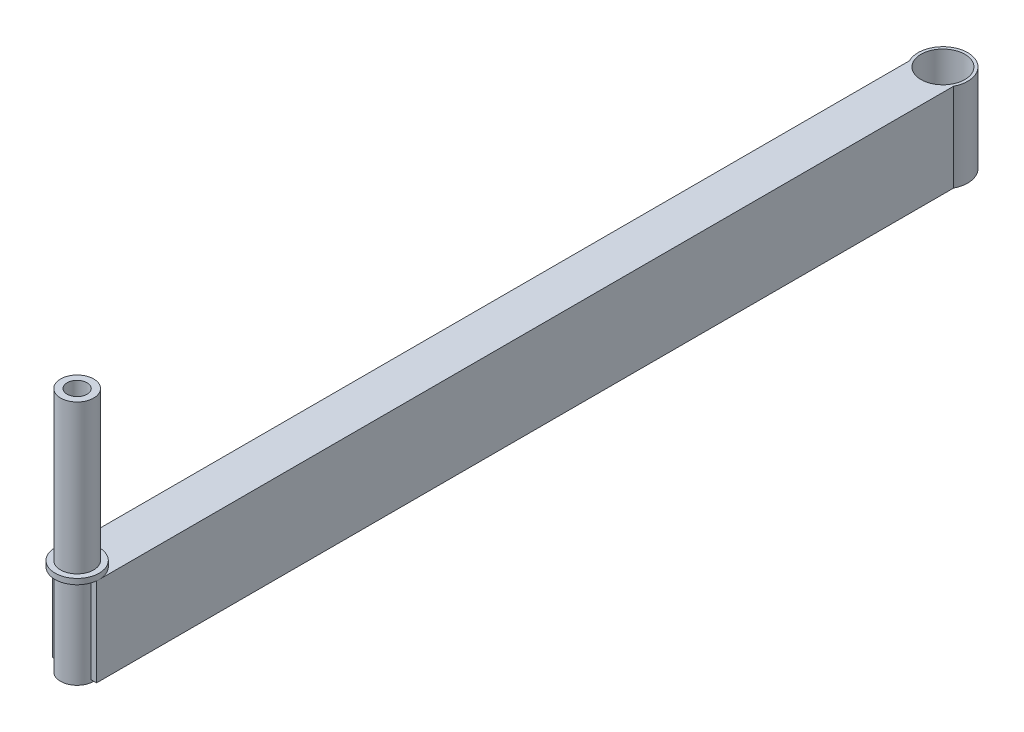
from build123d import *

# Parameters (mm, degrees)
SKETCH1_W                       = 25.4
SKETCH1_H                       = 50.8
SKETCH1_W_2                     = 22.2504
SKETCH1_H_2                     = 47.6504
BOSS_EXTRUDE1_DEPTH             = 498.475
SKETCH2_R                       = 14.2875
SKETCH2_R_2                     = 9.525
CUT_EXTRUDE1_DEPTH              = 51.8
SKETCH3_R                       = 14.2875
SKETCH3_R_2                     = 12.6365
BOSS_EXTRUDE2_DEPTH             = 50.8
SKETCH4_R                       = 9.525
SKETCH4_R_2                     = 6.35
BOSS_EXTRUDE3_DEPTH             = 88.9
BOSS_EXTRUDE3_DEPTH_BACK        = 52.3875
SKETCH5_R                       = 12.7
SKETCH5_R_2                     = 9.525
BOSS_EXTRUDE4_DEPTH             = 3.175
SKETCH6_R                       = 6.35
BOSS_EXTRUDE5_DEPTH             = 19.05
TAP_DRILL_FOR_1_2_20_TAP1_D     = 11.50874
TAP_DRILL_FOR_1_2_20_TAP1_DEPTH = 19.05
BOSS_EXTRUDE6_REACH             = 28.987
SKETCH9_W                       = 1.524
SKETCH9_H                       = 50.8
BOSS_EXTRUDE7_REACH             = 28.988
SKETCH10_W                      = 1.524
SKETCH10_H                      = 50.8


with BuildPart() as part:
    # Sketch1 → Boss-Extrude1 (new body)
    with BuildSketch(Plane.XY):
        Rectangle(SKETCH1_W, SKETCH1_H)
        Rectangle(SKETCH1_W_2, SKETCH1_H_2, mode=Mode.SUBTRACT)
    extrude(amount=BOSS_EXTRUDE1_DEPTH)

    # Sketch2 → Cut-Extrude1 (cut, through all)
    with BuildSketch(Plane(origin=(0, 25.4, 0), x_dir=(1, 0, 0), z_dir=(0, 1, 0))):
        Circle(SKETCH2_R)
        with Locations((0, -498.475)):
            Circle(SKETCH2_R_2)
    extrude(amount=-CUT_EXTRUDE1_DEPTH, mode=Mode.SUBTRACT)

    # Sketch3 → Boss-Extrude2 (add)
    with BuildSketch(Plane(origin=(0, 25.4, 0), x_dir=(1, 0, 0), z_dir=(0, 1, 0))):
        Circle(SKETCH3_R)
        Circle(SKETCH3_R_2, mode=Mode.SUBTRACT)
    extrude(amount=-BOSS_EXTRUDE2_DEPTH)

    # Sketch4 → Boss-Extrude3 (add, two sides)
    with BuildSketch(Plane(origin=(0, 25.4, 0), x_dir=(1, 0, 0), z_dir=(0, 1, 0))) as boss_extrude3_sk:
        with Locations((0, -498.475)):
            Circle(SKETCH4_R)
        with Locations((0, -498.475)):
            Circle(SKETCH4_R_2, mode=Mode.SUBTRACT)
    extrude(amount=BOSS_EXTRUDE3_DEPTH)
    extrude(boss_extrude3_sk.sketch, amount=-BOSS_EXTRUDE3_DEPTH_BACK)

    # Sketch5 → Boss-Extrude4 (add)
    with BuildSketch(Plane(origin=(0, 25.4, 0), x_dir=(1, 0, 0), z_dir=(0, 1, 0))):
        with Locations((0, -498.475)):
            Circle(SKETCH5_R)
        with Locations((0, -498.475)):
            Circle(SKETCH5_R_2, mode=Mode.SUBTRACT)
    extrude(amount=BOSS_EXTRUDE4_DEPTH)

    # Sketch6 → Boss-Extrude5 (add)
    with BuildSketch(Plane(origin=(0, 114.3, 0), x_dir=(1, 0, 0), z_dir=(0, 1, 0))):
        with Locations((0, -498.475)):
            Circle(SKETCH6_R)
    extrude(amount=-BOSS_EXTRUDE5_DEPTH)

    # Tap Drill for 1_2-20 Tap1
    with Locations(Plane(origin=(0, 114.3, 0), x_dir=(1, 0, 0), z_dir=(0, 1, 0))):
        with Locations((0, -498.475)):
            Hole(TAP_DRILL_FOR_1_2_20_TAP1_D / 2, depth=TAP_DRILL_FOR_1_2_20_TAP1_DEPTH)

    # Sketch9 → Boss-Extrude6 (add, up to next)
    with BuildSketch(Plane(origin=(12.7, 0, 0), x_dir=(0, 0, -1), z_dir=(1, 0, 0)), mode=Mode.PRIVATE) as boss_extrude6_sk1:
        with Locations((-499.237, 0)):
            Rectangle(SKETCH9_W, SKETCH9_H)
    boss_extrude6_tool1 = extrude(boss_extrude6_sk1.sketch, amount=-BOSS_EXTRUDE6_REACH, mode=Mode.PRIVATE) - part.part
    add(boss_extrude6_tool1.solids().sort_by_distance((12.7, 0, 499.237))[0])

    # Sketch10 → Boss-Extrude7 (add, up to next)
    with BuildSketch(Plane.ZY.offset(12.7), mode=Mode.PRIVATE) as boss_extrude7_sk1:
        with Locations((499.237, 0)):
            Rectangle(SKETCH10_W, SKETCH10_H)
    boss_extrude7_tool1 = extrude(boss_extrude7_sk1.sketch, amount=-BOSS_EXTRUDE7_REACH, mode=Mode.PRIVATE) - part.part
    add(boss_extrude7_tool1.solids().sort_by_distance((-12.7, 0, 499.237))[0])


solid = part.part
